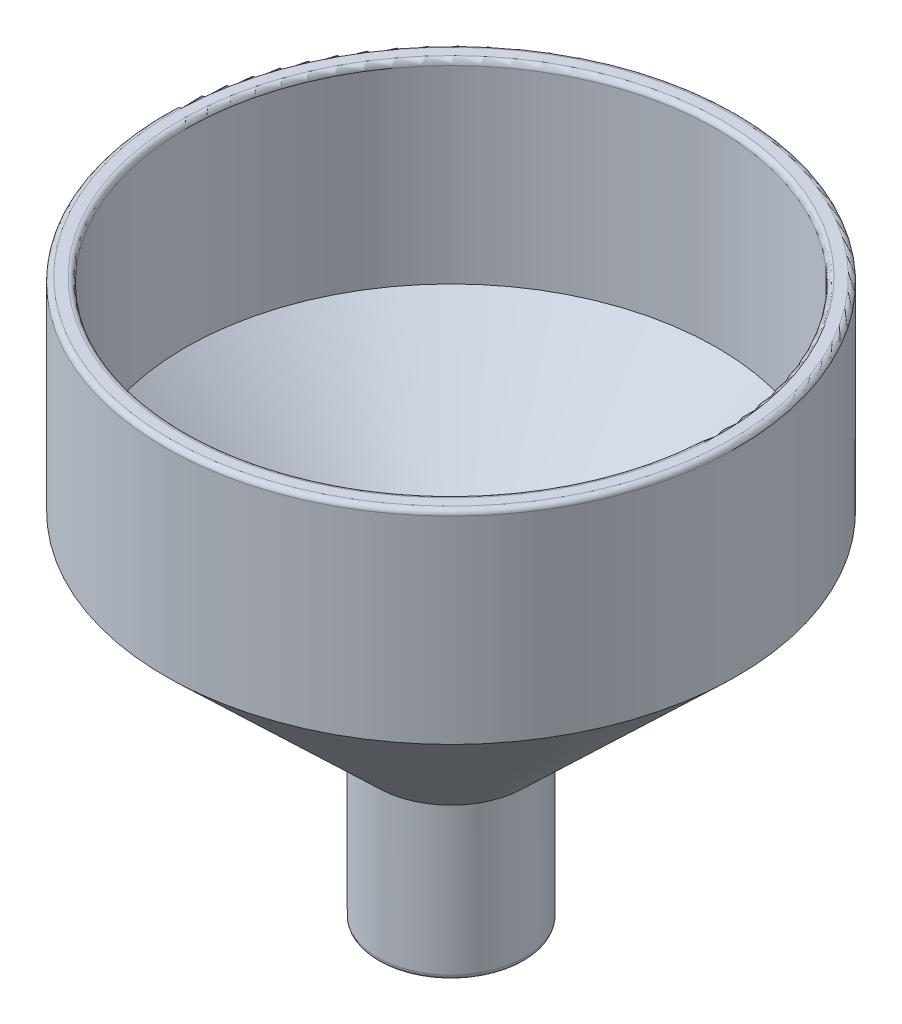
from build123d import *

# Parameters (mm, degrees)
FILLET1_R = 0.5


with BuildPart() as part:
    # Sketch1 → Revolve1 (revolve)
    with BuildSketch(Plane.XY):
        Polygon((-5.25, 15.08330694), (-5.25, 30.939040938), (-26.2, 50.939040938), (-26.2, 70.08330694), (-28.2, 70.08330694), (-28.2, 50.08330694), (-7.25, 30.08330694), (-7.25, 15.08330694), align=None)
    revolve(axis=Axis((0, 0, 0), (0, 1, 0)))

    # Fillet1
    fillet1_edges = [part.edges().sort_by_distance(p)[0] for p in [
        (7.25, 15.08330694, 0),
        (28.2, 70.08330694, 0),
        (26.2, 70.08330694, 0),
        (5.25, 15.08330694, 0),
    ]]
    fillet(fillet1_edges, radius=FILLET1_R)


solid = part.part
